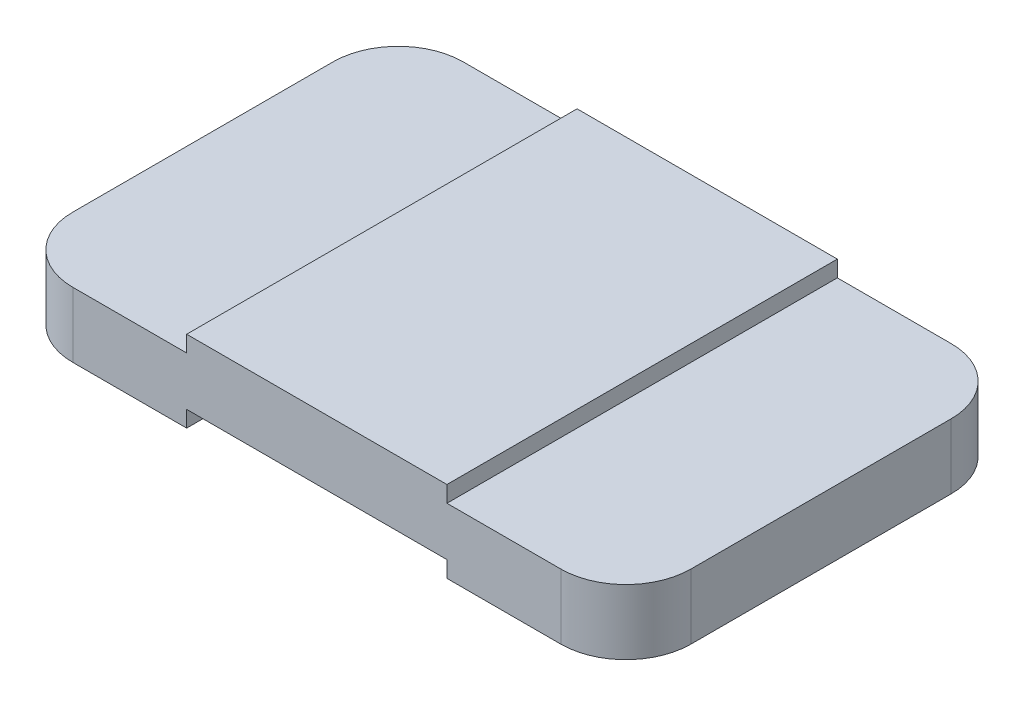
from build123d import *

# Parameters (mm, degrees)
BOSS_EXTRUDE1_DEPTH = 3
FILLET1_R           = 0.5


with BuildPart() as part:
    # Sketch1 → Boss-Extrude1 (new body)
    with BuildSketch(Plane.XY):
        Polygon((0, 0), (1.375, 0), (1.375, 0.125), (3.375, 0.125), (3.375, 0), (4.75, 0), (4.75, 0.5), (3.375, 0.5), (3.375, 0.625), (1.375, 0.625), (1.375, 0.5), (0, 0.5), align=None)
    extrude(amount=-BOSS_EXTRUDE1_DEPTH)

    # Fillet1
    fillet1_edges = [part.edges().sort_by_distance(p)[0] for p in [
        (4.75, 0.25, 0),
        (0, 0.25, 0),
        (4.75, 0.25, -3),
        (0, 0.25, -3),
    ]]
    fillet(fillet1_edges, radius=FILLET1_R)


solid = part.part
